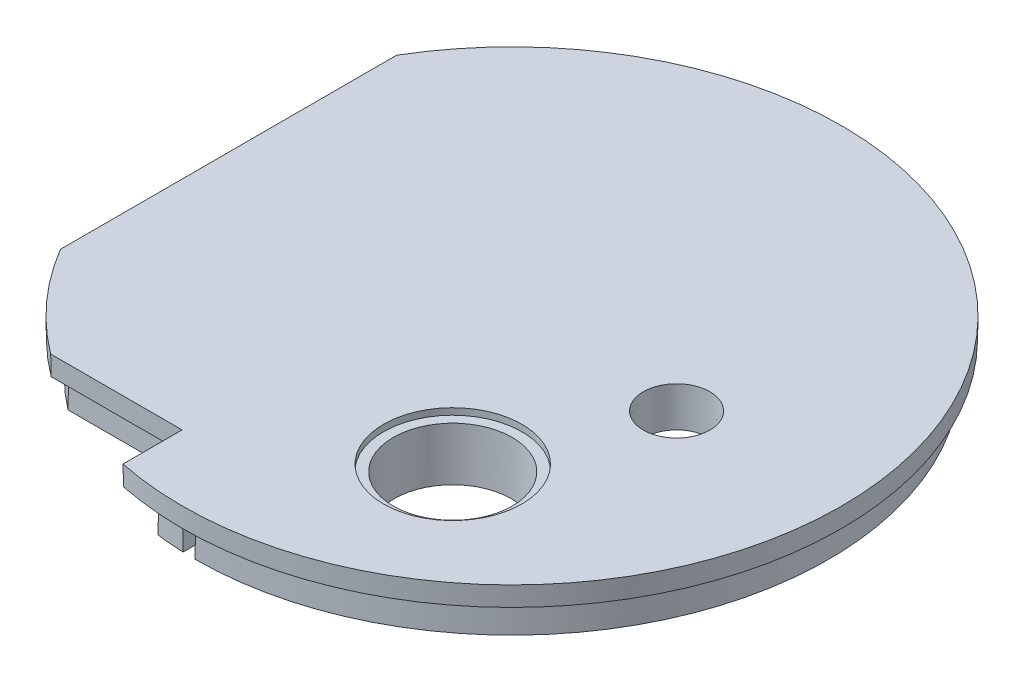
from build123d import *

# Parameters (mm, degrees)
BOSS_EXTRUDE1_DEPTH           = 3
BOSS_EXTRUDE1_DRAFT           = -1
BOSS_EXTRUDE2_DEPTH           = 5
BOSS_EXTRUDE2_DRAFT           = -1
BOSS_EXTRUDE2_PROFILE_2_DEPTH = 5
BOSS_EXTRUDE2_PROFILE_2_DRAFT = -1
BOSS_EXTRUDE2_PROFILE_3_DEPTH = 5
BOSS_EXTRUDE2_PROFILE_3_DRAFT = -1
BOSS_EXTRUDE2_PROFILE_4_DEPTH = 5
BOSS_EXTRUDE2_PROFILE_4_DRAFT = -1
SKETCH3_R                     = 5
CUT_EXTRUDE1_DEPTH            = 3
CUT_EXTRUDE1_DRAFT            = 1
SKETCH3_R_2                   = 9
CUT_EXTRUDE1_PROFILE_2_DEPTH  = 3
CUT_EXTRUDE1_PROFILE_2_DRAFT  = 1
SKETCH4_R                     = 9
SKETCH4_R_2                   = 8
BOSS_EXTRUDE3_DEPTH           = 3
BOSS_EXTRUDE3_DRAFT           = -1
SKETCH4_3_R                   = 6
SKETCH4_3_R_2                 = 5
BOSS_EXTRUDE4_DEPTH           = 3
BOSS_EXTRUDE4_DRAFT           = -1
SKETCH6_R                     = 10.5
SKETCH6_R_2                   = 9
BOSS_EXTRUDE5_DEPTH           = 6
BOSS_EXTRUDE5_DRAFT           = -1
SKETCH7_R                     = 10.5
SKETCH7_R_2                   = 9
CUT_EXTRUDE2_DEPTH            = 1
CUT_EXTRUDE2_DRAFT            = 1


with BuildPart() as part:
    # Sketch1 → Boss-Extrude1 (with draft: the straight prism first)
    with BuildSketch(Plane(origin=(0, 0, 0), x_dir=(1, 0, 0), z_dir=(0, 1, 0))):
        with BuildLine():
            Line((-43, 25.514701644), (-43, -25.514701644))
            ThreePointArc((-43, -25.514701644), (-37.211637523, -33.396018219), (-30, -40))
            Line((-30, -40), (-10, -40))
            Line((-10, -40), (-10, -48.989794856))
            ThreePointArc((-10, -48.989794856), (45.716299059, 20.248950598), (-43, 25.514701644))
        make_face()
    extrude(amount=BOSS_EXTRUDE1_DEPTH)
    # Boss-Extrude1: the draft: its side faces are tilted about the plane it starts from
    boss_extrude1_sides = [part.faces().sort_by_distance(p)[0] for p in [
        (-43, 1.5, 0),
        (-37.211637523, 1.5, 33.396018219),
        (-20, 1.5, 40),
        (-10, 1.5, 44.494897428),
        (45.716299059, 1.5, -20.248950598),
    ]]
    draft(boss_extrude1_sides, Plane(origin=(0, 0, 0), x_dir=(1, 0, 0), z_dir=(0, 1, 0)), BOSS_EXTRUDE1_DRAFT)


with BuildPart() as boss_extrude2_tool:
    # Sketch2 → Boss-Extrude2 (with draft: the straight prism first)
    with BuildSketch(Plane.XZ):
        with BuildLine():
            Line((-40.978122, 24.995870006), (-40.978122, -24.995870006))
            ThreePointArc((-40.978122, -24.995870006), (-26.914721681, -39.744153744), (-8, -47.328638265))
            Line((-8, -47.328638265), (-8, -45.299006612))
            ThreePointArc((-8, -45.299006612), (-25.702922785, -38.149177715), (-38.978122, -24.427566505))
            Line((-38.978122, -24.427566505), (-38.978122, 24.427566505))
            ThreePointArc((-38.978122, 24.427566505), (-34.298477795, 30.653130687), (-28.635642127, 36))
            Line((-28.635642127, 36), (-8, 36))
            Line((-8, 36), (-8, 38))
            Line((-8, 38), (-29.325756597, 38))
            ThreePointArc((-29.325756597, 38), (-35.748226329, 32.032238672), (-40.978122, 24.995870006))
        make_face()
    extrude(amount=BOSS_EXTRUDE2_DEPTH)
    # Boss-Extrude2: the draft: its side faces are tilted about the plane it starts from
    boss_extrude2_sides = [boss_extrude2_tool.faces().sort_by_distance(p)[0] for p in [
        (-38.978122, -2.5, 0),
        (-34.298477795, -2.5, 30.653130687),
        (-18.317821063, -2.5, 36),
        (-8, -2.5, 37),
        (-18.662878299, -2.5, 38),
        (-35.748226329, -2.5, 32.032238672),
        (-40.978122, -2.5, 0),
        (-26.914721681, -2.5, -39.744153744),
        (-8, -2.5, -46.313822438),
        (-25.702922785, -2.5, -38.149177715),
    ]]
    draft(boss_extrude2_sides, Plane.XZ, BOSS_EXTRUDE2_DRAFT)


with BuildPart() as part_1:
    add(part.part)

    # Boss-Extrude2: add boss_extrude2_tool
    add(boss_extrude2_tool.part)


with BuildPart() as boss_extrude2_profile_2_tool:
    # Sketch2 → Boss-Extrude2 profile 2 (with draft: the straight prism first)
    with BuildSketch(Plane.XZ):
        with BuildLine():
            ThreePointArc((-6, 45.607017004), (-4.00381503, 45.825423786), (-2, 45.956501172))
            Line((-2, 45.956501172), (-2, 47.958315233))
            ThreePointArc((-2, 47.958315233), (-4.003501138, 47.832750064), (-6, 47.623523599))
            Line((-6, 47.623523599), (-6, 45.607017004))
        make_face()
    extrude(amount=BOSS_EXTRUDE2_PROFILE_2_DEPTH)
    # Boss-Extrude2 profile 2: the draft: its side faces are tilted about the plane it starts from
    boss_extrude2_profile_2_sides = [boss_extrude2_profile_2_tool.faces().sort_by_distance(p)[0] for p in [
        (-4.00381503, -2.5, 45.825423786),
        (-2, -2.5, 46.957408203),
        (-4.003501138, -2.5, 47.832750064),
        (-6, -2.5, 46.615270302),
    ]]
    draft(boss_extrude2_profile_2_sides, Plane.XZ, BOSS_EXTRUDE2_PROFILE_2_DRAFT)


with BuildPart() as part_2:
    add(part_1.part)

    # Boss-Extrude2 profile 2: add boss_extrude2_profile_2_tool
    add(boss_extrude2_profile_2_tool.part)


with BuildPart() as boss_extrude2_profile_3_tool:
    # Sketch2 → Boss-Extrude2 profile 3 (with draft: the straight prism first)
    with BuildSketch(Plane.XZ):
        with BuildLine():
            Line((-6, -45.607017004), (-6, -47.623523599))
            ThreePointArc((-6, -47.623523599), (-4.003501138, -47.832750064), (-2, -47.958315233))
            Line((-2, -47.958315233), (-2, -45.956501172))
            ThreePointArc((-2, -45.956501172), (-4.00381503, -45.825423786), (-6, -45.607017004))
        make_face()
    extrude(amount=BOSS_EXTRUDE2_PROFILE_3_DEPTH)
    # Boss-Extrude2 profile 3: the draft: its side faces are tilted about the plane it starts from
    boss_extrude2_profile_3_sides = [boss_extrude2_profile_3_tool.faces().sort_by_distance(p)[0] for p in [
        (-4.00381503, -2.5, -45.825423786),
        (-6, -2.5, -46.615270302),
        (-4.003501138, -2.5, -47.832750064),
        (-2, -2.5, -46.957408203),
    ]]
    draft(boss_extrude2_profile_3_sides, Plane.XZ, BOSS_EXTRUDE2_PROFILE_3_DRAFT)


with BuildPart() as part_3:
    add(part_2.part)

    # Boss-Extrude2 profile 3: add boss_extrude2_profile_3_tool
    add(boss_extrude2_profile_3_tool.part)


with BuildPart() as boss_extrude2_profile_4_tool:
    # Sketch2 → Boss-Extrude2 profile 4 (with draft: the straight prism first)
    with BuildSketch(Plane.XZ):
        with BuildLine():
            ThreePointArc((0, 46), (46, 0), (0, -46))
            Line((0, -46), (0, -48))
            ThreePointArc((0, -48), (48, 0), (0, 48))
            Line((0, 48), (0, 46))
        make_face()
    extrude(amount=BOSS_EXTRUDE2_PROFILE_4_DEPTH)
    # Boss-Extrude2 profile 4: the draft: its side faces are tilted about the plane it starts from
    boss_extrude2_profile_4_sides = [boss_extrude2_profile_4_tool.faces().sort_by_distance(p)[0] for p in [
        (0, -2.5, -47),
        (48, -2.5, 0),
        (0, -2.5, 47),
        (46, -2.5, 0),
    ]]
    draft(boss_extrude2_profile_4_sides, Plane.XZ, BOSS_EXTRUDE2_PROFILE_4_DRAFT)


with BuildPart() as part_4:
    add(part_3.part)

    # Boss-Extrude2 profile 4: add boss_extrude2_profile_4_tool
    add(boss_extrude2_profile_4_tool.part)


with BuildPart() as cut_extrude1_tool:
    # Sketch3 → Cut-Extrude1 (with draft: the straight prism first)
    with BuildSketch(Plane.XZ):
        with Locations((25, 0)):
            Circle(SKETCH3_R)
    extrude(amount=-CUT_EXTRUDE1_DEPTH)
    # Cut-Extrude1: the draft: its side faces are tilted about the plane it starts from
    cut_extrude1_sides = [cut_extrude1_tool.faces().sort_by_distance(p)[0] for p in [
        (20, 1.5, 0),
    ]]
    draft(cut_extrude1_sides, Plane.XZ, CUT_EXTRUDE1_DRAFT)


with BuildPart() as part_5:
    add(part_4.part)

    # Cut-Extrude1: cut by cut_extrude1_tool
    add(cut_extrude1_tool.part, mode=Mode.SUBTRACT)


with BuildPart() as cut_extrude1_profile_2_tool:
    # Sketch3 → Cut-Extrude1 profile 2 (with draft: the straight prism first)
    with BuildSketch(Plane.XZ):
        with Locations((15, 24)):
            Circle(SKETCH3_R_2)
    extrude(amount=-CUT_EXTRUDE1_PROFILE_2_DEPTH)
    # Cut-Extrude1 profile 2: the draft: its side faces are tilted about the plane it starts from
    cut_extrude1_profile_2_sides = [cut_extrude1_profile_2_tool.faces().sort_by_distance(p)[0] for p in [
        (6, 1.5, 24),
    ]]
    draft(cut_extrude1_profile_2_sides, Plane.XZ, CUT_EXTRUDE1_PROFILE_2_DRAFT)


with BuildPart() as part_6:
    add(part_5.part)

    # Cut-Extrude1 profile 2: cut by cut_extrude1_profile_2_tool
    add(cut_extrude1_profile_2_tool.part, mode=Mode.SUBTRACT)


with BuildPart() as boss_extrude3_tool:
    # Sketch4 → Boss-Extrude3 (with draft: the straight prism first)
    with BuildSketch(Plane.XZ):
        with Locations((25, 0)):
            Circle(SKETCH4_R)
        with Locations((25, 0)):
            Circle(SKETCH4_R_2, mode=Mode.SUBTRACT)
    extrude(amount=BOSS_EXTRUDE3_DEPTH)
    # Boss-Extrude3: the draft: its side faces are tilted about the plane it starts from
    boss_extrude3_sides = [boss_extrude3_tool.faces().sort_by_distance(p)[0] for p in [
        (16, -1.5, 0),
        (17, -1.5, 0),
    ]]
    draft(boss_extrude3_sides, Plane.XZ, BOSS_EXTRUDE3_DRAFT)


with BuildPart() as part_7:
    add(part_6.part)

    # Boss-Extrude3: add boss_extrude3_tool
    add(boss_extrude3_tool.part)


with BuildPart() as boss_extrude4_tool:
    # Sketch4_3 → Boss-Extrude4 (with draft: the straight prism first)
    with BuildSketch(Plane.XZ):
        with Locations((25, 0)):
            Circle(SKETCH4_3_R)
        with Locations((25, 0)):
            Circle(SKETCH4_3_R_2, mode=Mode.SUBTRACT)
    extrude(amount=BOSS_EXTRUDE4_DEPTH)
    # Boss-Extrude4: the draft: its side faces are tilted about the plane it starts from
    boss_extrude4_sides = [boss_extrude4_tool.faces().sort_by_distance(p)[0] for p in [
        (19, -1.5, 0),
        (20, -1.5, 0),
    ]]
    draft(boss_extrude4_sides, Plane.XZ, BOSS_EXTRUDE4_DRAFT)


with BuildPart() as part_8:
    add(part_7.part)

    # Boss-Extrude4: add boss_extrude4_tool
    add(boss_extrude4_tool.part)


with BuildPart() as boss_extrude5_tool:
    # Sketch6 → Boss-Extrude5 (with draft: the straight prism first)
    with BuildSketch(Plane.XZ):
        with Locations((15, 24)):
            Circle(SKETCH6_R)
        with Locations((15, 24)):
            Circle(SKETCH6_R_2, mode=Mode.SUBTRACT)
    extrude(amount=BOSS_EXTRUDE5_DEPTH)
    # Boss-Extrude5: the draft: its side faces are tilted about the plane it starts from
    boss_extrude5_sides = [boss_extrude5_tool.faces().sort_by_distance(p)[0] for p in [
        (4.5, -3, 24),
        (6, -3, 24),
    ]]
    draft(boss_extrude5_sides, Plane.XZ, BOSS_EXTRUDE5_DRAFT)


with BuildPart() as part_9:
    add(part_8.part)

    # Boss-Extrude5: add boss_extrude5_tool
    add(boss_extrude5_tool.part)


with BuildPart() as cut_extrude2_tool:
    # Sketch7 → Cut-Extrude2 (with draft: the straight prism first)
    with BuildSketch(Plane(origin=(0, 3, 0), x_dir=(1, 0, 0), z_dir=(0, 1, 0))):
        with Locations((15, -24)):
            Circle(SKETCH7_R)
        with Locations((15, -24)):
            Circle(SKETCH7_R_2, mode=Mode.SUBTRACT)
    extrude(amount=-CUT_EXTRUDE2_DEPTH)
    # Cut-Extrude2: the draft: its side faces are tilted about the plane it starts from
    cut_extrude2_sides = [cut_extrude2_tool.faces().sort_by_distance(p)[0] for p in [
        (4.5, 2.5, 24),
        (6, 2.5, 24),
    ]]
    draft(cut_extrude2_sides, Plane(origin=(0, 3, 0), x_dir=(1, 0, 0), z_dir=(0, 1, 0)), CUT_EXTRUDE2_DRAFT)


with BuildPart() as part_10:
    add(part_9.part)

    # Cut-Extrude2: cut by cut_extrude2_tool
    add(cut_extrude2_tool.part, mode=Mode.SUBTRACT)


solid = part_10.part
